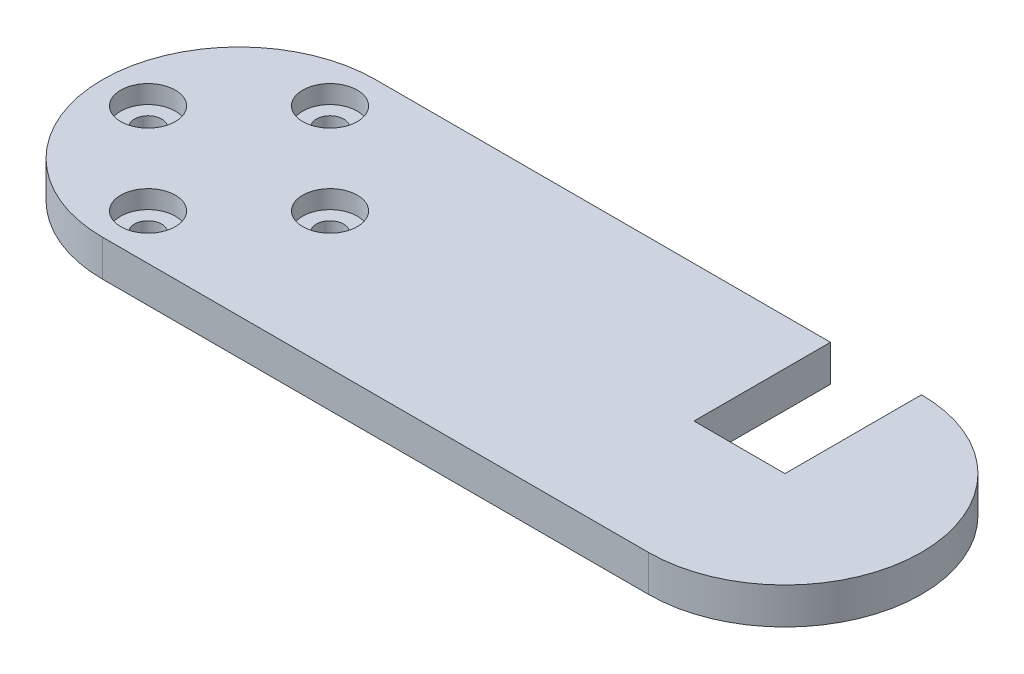
from build123d import *

# Parameters (mm, degrees)
BOSS_EXTRUDE1_DEPTH = 4
SKETCH2_W           = 10
SKETCH2_H           = 15
CUT_EXTRUDE1_DEPTH  = 4
SKETCH3_R           = 3
CUT_EXTRUDE2_DEPTH  = 2
SKETCH4_R           = 1.5
CUT_EXTRUDE3_DEPTH  = 2


with BuildPart() as part:
    # Sketch1 → Boss-Extrude1 (new body)
    with BuildSketch(Plane(origin=(0, 0, 0), x_dir=(1, 0, 0), z_dir=(0, 1, 0))):
        with BuildLine():
            Line((0, 15), (60, 15))
            ThreePointArc((60, 15), (75, 0), (60, -15))
            Line((60, -15), (0, -15))
            ThreePointArc((0, -15), (-15, 0), (0, 15))
        make_face()
    extrude(amount=BOSS_EXTRUDE1_DEPTH)

    # Sketch2 → Cut-Extrude1 (cut)
    with BuildSketch(Plane(origin=(0, 4, 0), x_dir=(1, 0, 0), z_dir=(0, 1, 0))):
        with Locations((55, 7.5)):
            Rectangle(SKETCH2_W, SKETCH2_H)
    extrude(amount=-CUT_EXTRUDE1_DEPTH, mode=Mode.SUBTRACT)

    # Sketch3 → Cut-Extrude2 (cut)
    with BuildSketch(Plane(origin=(0, 4, 0), x_dir=(1, 0, 0), z_dir=(0, 1, 0))):
        with Locations((-10, 0)):
            Circle(SKETCH3_R)
        with Locations((0, 10)):
            Circle(SKETCH3_R)
        with Locations((10, 0)):
            Circle(SKETCH3_R)
        with Locations((0, -10)):
            Circle(SKETCH3_R)
    extrude(amount=-CUT_EXTRUDE2_DEPTH, mode=Mode.SUBTRACT)

    # Sketch4 → Cut-Extrude3 (cut)
    with BuildSketch(Plane(origin=(0, 2, 0), x_dir=(1, 0, 0), z_dir=(0, 1, 0))):
        with Locations((-10, 0)):
            Circle(SKETCH4_R)
        with Locations((0, 10)):
            Circle(SKETCH4_R)
        with Locations((10, 0)):
            Circle(SKETCH4_R)
        with Locations((0, -10)):
            Circle(SKETCH4_R)
    extrude(amount=-CUT_EXTRUDE3_DEPTH, mode=Mode.SUBTRACT)


solid = part.part
